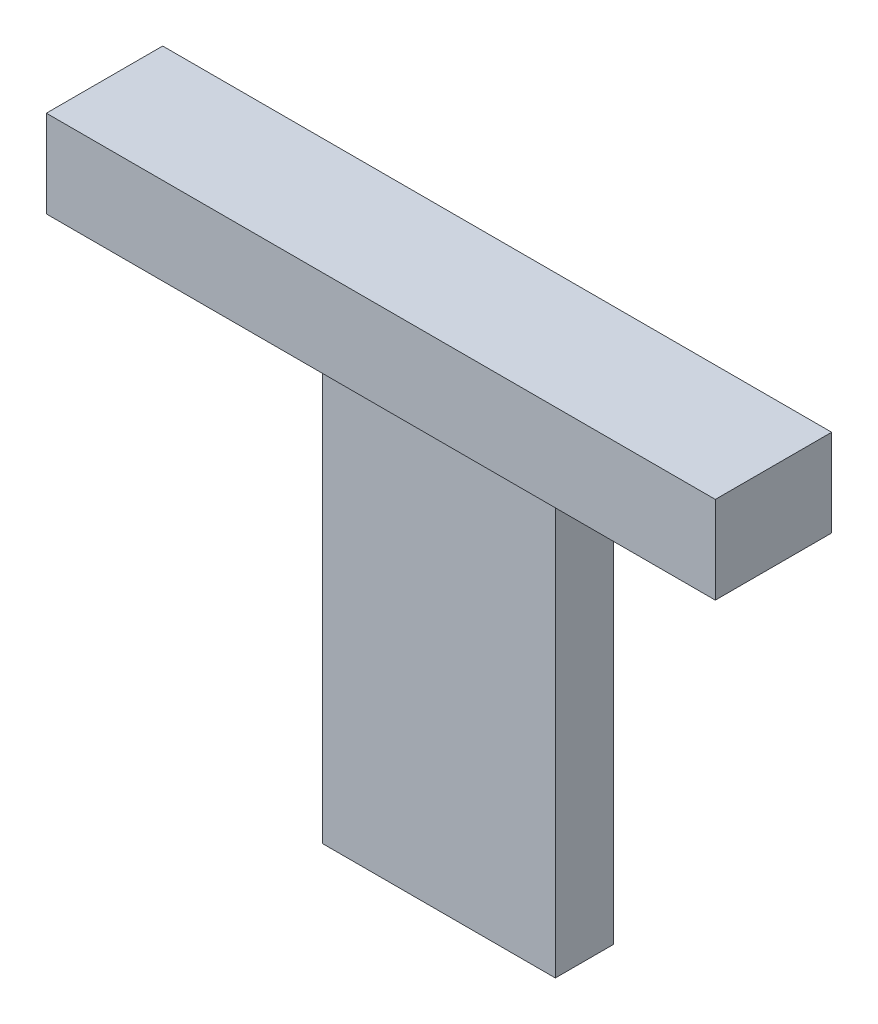
from build123d import *

# Parameters (mm, degrees)
SKETCH1_W           = 80
SKETCH1_H           = 160
BOSS_EXTRUDE1_DEPTH = 20
BOSS_EXTRUDE2_DEPTH = 40


with BuildPart() as part:
    # Sketch1 → Boss-Extrude1 (new body)
    with BuildSketch(Plane.XY):
        Rectangle(SKETCH1_W, SKETCH1_H)
    extrude(amount=BOSS_EXTRUDE1_DEPTH)

    # Sketch1_3 → Boss-Extrude2 (add)
    with BuildSketch(Plane.XY):
        Polygon((-115, 80), (-40, 80), (40, 80), (115, 80), (115, 110), (-115, 110), align=None)
    extrude(amount=BOSS_EXTRUDE2_DEPTH)


solid = part.part
